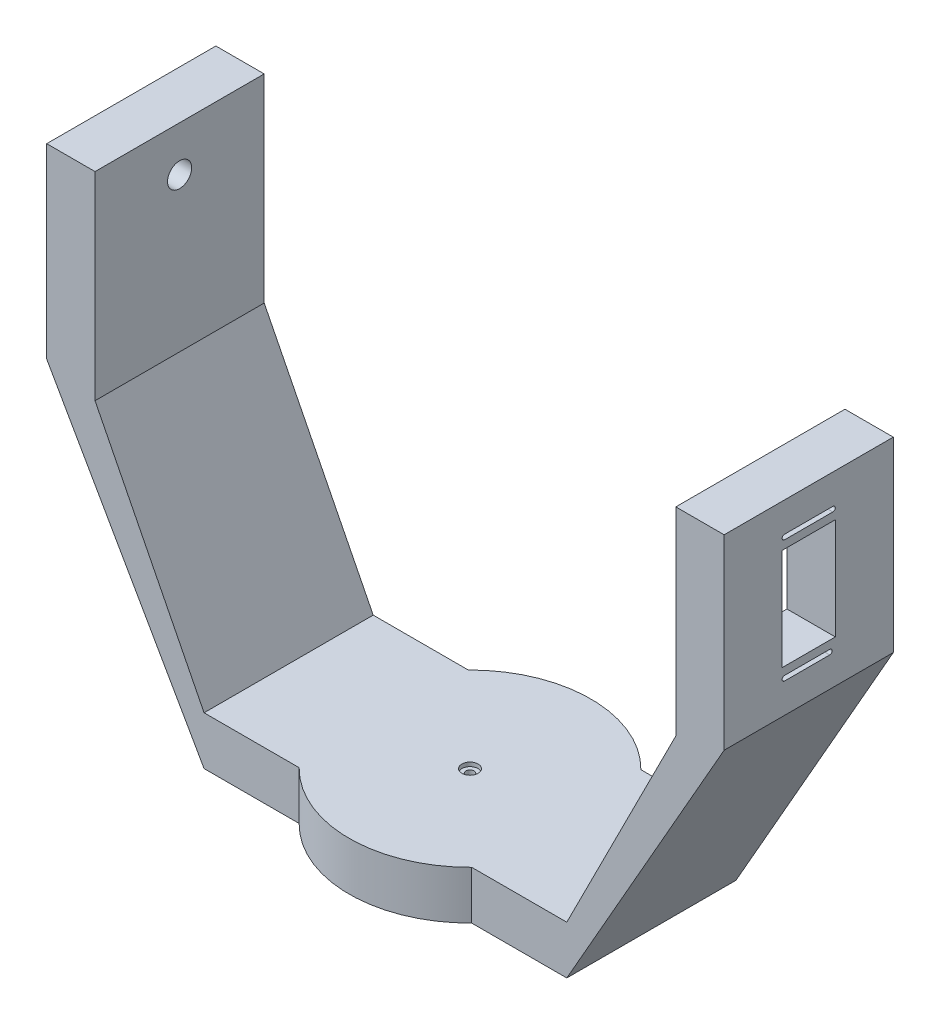
from build123d import *

# Parameters (mm, degrees)
EXTRUDE_1_DEPTH        = 20
EXTRUDE_2_DEPTH        = 70
F_1_4_BASE_D           = 3.4
F_1_4_BASE_CBORE_D     = 6.7
F_1_4_BASE_CBORE_DEPTH = 1.65
SKETCH_11_W            = 22
SKETCH_11_H            = 42
CUT_EXTRUDE_1_DEPTH    = 32
CUT_EXTRUDE_2_DEPTH    = 67
SKETCH_15_R            = 5
CUT_EXTRUDE_3_DEPTH    = 70
CUT_EXTRUDE_4_DEPTH    = 2
CUT_EXTRUDE_5_DEPTH    = 3.5


with BuildPart() as part:
    # 草图1 → 凸台-拉伸1 (new body)
    with BuildSketch(Plane(origin=(0, 0, 0), x_dir=(1, 0, 0), z_dir=(0, 1, 0))):
        with BuildLine():
            Line((75.055476805, 35), (35.707142143, 35))
            ThreePointArc((35.707142143, 35), (46.289075964, 18.902948088), (50, 0))
            ThreePointArc((50, 0), (46.289075964, -18.902948088), (35.707142143, -35))
            Line((35.707142143, -35), (75.055476805, -35))
            Line((75.055476805, -35), (75.055476805, 35))
        make_face()
        with BuildLine():
            Line((0.055476805, -35), (0.055476805, 35))
            Line((0.055476805, 35), (35.707142143, 35))
            ThreePointArc((35.707142143, 35), (-50, 0), (35.707142143, -35))
            Line((35.707142143, -35), (0.055476805, -35))
        make_face()
        with BuildLine():
            Line((35.707142143, 35), (0.055476805, 35))
            Line((0.055476805, 35), (0.055476805, -35))
            Line((0.055476805, -35), (35.707142143, -35))
            ThreePointArc((35.707142143, -35), (46.289075964, -18.902948088), (50, 0))
            ThreePointArc((50, 0), (46.289075964, 18.902948088), (35.707142143, 35))
        make_face()
    extrude_1 = extrude(amount=EXTRUDE_1_DEPTH)

    # 草图2 → 凸台-拉伸2 (add)
    with BuildSketch(Plane.XY.offset(35)):
        Polygon((75.055476805, 0), (140.174133177, 114.192122372), (140.174133177, 191.411564081), (120.174133177, 191.411564081), (120.174133177, 109.286292207), (75.055476805, 20), align=None)
    extrude_2 = extrude(amount=-EXTRUDE_2_DEPTH)

    # 镜向1: 凸台-拉伸1, 凸台-拉伸2 across plane
    add(extrude_1.mirror(Plane(origin=(0, 0, 0), x_dir=(0, 0, 1), z_dir=(1, 0, 0))))
    add(extrude_2.mirror(Plane(origin=(0, 0, 0), x_dir=(0, 0, 1), z_dir=(1, 0, 0))))

    # 1/4 六角头螺钉的柱形沉头孔base (through all)
    with Locations(Plane(origin=(0, 20, 0), x_dir=(1, 0, 0), z_dir=(0, 1, 0))):
        with Locations((0, 0)):
            CounterBoreHole(F_1_4_BASE_D / 2, F_1_4_BASE_CBORE_D / 2, F_1_4_BASE_CBORE_DEPTH)

    # 草图11 → 切除-拉伸1 (cut)
    with BuildSketch(Plane(origin=(140.174133177, 0, 0), x_dir=(0, 0, -1), z_dir=(1, 0, 0))):
        with Locations((0, 152.801564081)):
            Rectangle(SKETCH_11_W, SKETCH_11_H)
    extrude(amount=-CUT_EXTRUDE_1_DEPTH, mode=Mode.SUBTRACT)

    # 草图14 → 切除-拉伸2 (cut)
    with BuildSketch(Plane(origin=(140.174133177, 0, 0), x_dir=(0, 0, -1), z_dir=(1, 0, 0))):
        with BuildLine():
            Line((-10, 179.101564081), (10, 179.101564081))
            ThreePointArc((10, 179.101564081), (11, 178.101564081), (10, 177.101564081))
            Line((10, 177.101564081), (-10, 177.101564081))
            ThreePointArc((-10, 177.101564081), (-11, 178.101564081), (-10, 179.101564081))
        make_face()
        with BuildLine():
            Line((-10, 128.501564081), (8.706275956, 128.501564081))
            ThreePointArc((8.706275956, 128.501564081), (9.706275956, 127.501564081), (8.706275956, 126.501564081))
            Line((8.706275956, 126.501564081), (-10, 126.501564081))
            ThreePointArc((-10, 126.501564081), (-11, 127.501564081), (-10, 128.501564081))
        make_face()
    extrude(amount=-CUT_EXTRUDE_2_DEPTH, mode=Mode.SUBTRACT)

    # 草图15 → 切除-拉伸3 (cut)
    with BuildSketch(Plane.ZY.offset(140.174133177)):
        with Locations((0, 172.801564081)):
            Circle(SKETCH_15_R)
    extrude(amount=-CUT_EXTRUDE_3_DEPTH, mode=Mode.SUBTRACT)

    # 草图16 → 切除-拉伸4 (cut)
    with BuildSketch(Plane.XZ):
        with BuildLine():
            Line((-30, 3), (0.784894819, 6.64557965))
            Line((0.784894819, 6.64557965), (31.544487342, 2.792338441))
            ThreePointArc((31.544487342, 2.792338441), (33.403111228, -0.103830779), (31.544487342, -3))
            Line((31.544487342, -3), (0.784894819, -6.64557965))
            Line((0.784894819, -6.64557965), (-30, -3))
            ThreePointArc((-30, -3), (-33, 0), (-30, 3))
        make_face()
    extrude(amount=-CUT_EXTRUDE_4_DEPTH, mode=Mode.SUBTRACT)

    # 草图17 → 切除-拉伸5 (cut)
    with BuildSketch(Plane.XZ):
        Polygon((0.784894819, 6.64557965), (-9.642246975, 5.410786542), (-9.642246975, -5.410786542), (0.784894819, -6.64557965), (11.20346648, -5.410786542), (11.20346648, 5.340449563), align=None)
    extrude(amount=-CUT_EXTRUDE_5_DEPTH, mode=Mode.SUBTRACT)


solid = part.part
